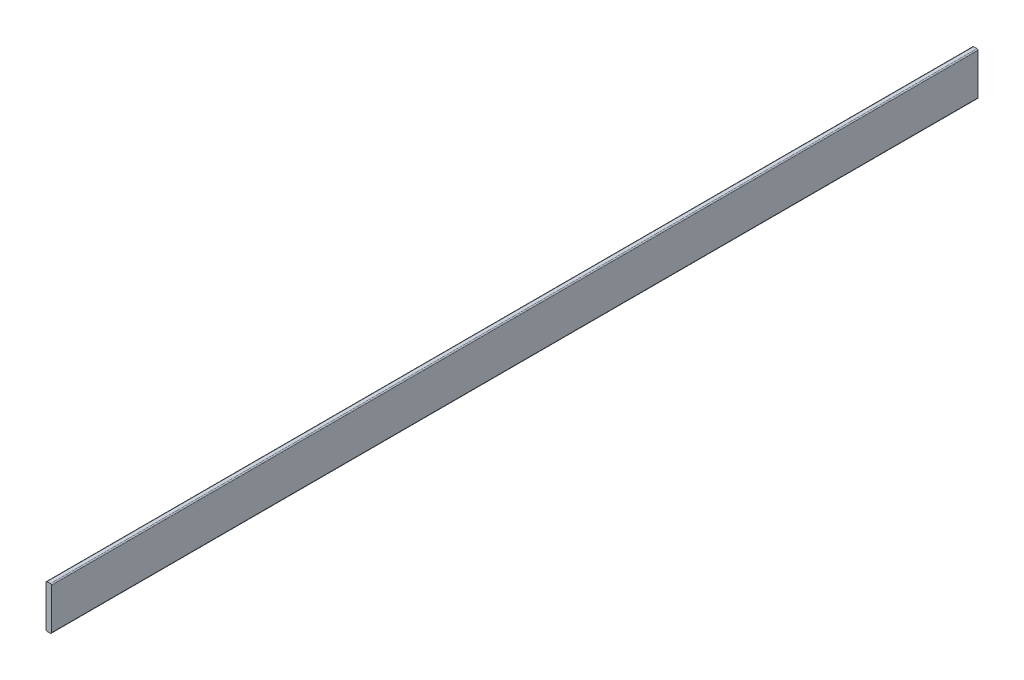
from build123d import *

# Parameters (mm, degrees)
BOSS_EXTRUDE1_DEPTH = 546.1


with BuildPart() as part:
    # Sketch1 → Boss-Extrude1 (new body)
    with BuildSketch(Plane.XY):
        with BuildLine():
            Line((0.635, 0), (2.54, 0))
            ThreePointArc((2.54, 0), (2.989012806, 0.185987194), (3.175, 0.635))
            Line((3.175, 0.635), (3.175, 24.765))
            ThreePointArc((3.175, 24.765), (2.989012806, 25.214012806), (2.54, 25.4))
            Line((2.54, 25.4), (0.635, 25.4))
            ThreePointArc((0.635, 25.4), (0.185987194, 25.214012806), (0, 24.765))
            Line((0, 24.765), (0, 0.635))
            ThreePointArc((0, 0.635), (0.185987194, 0.185987194), (0.635, 0))
        make_face()
    extrude(amount=BOSS_EXTRUDE1_DEPTH)


solid = part.part
